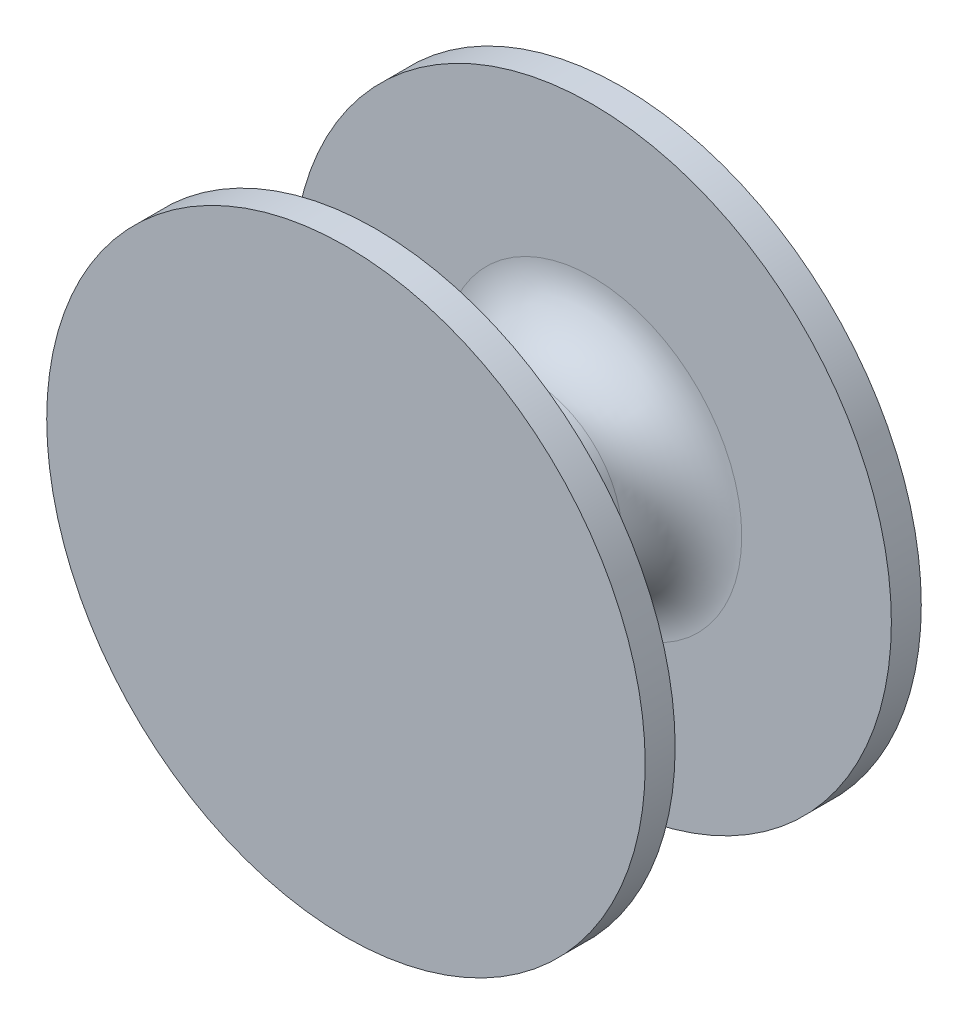
from build123d import *

# Parameters (mm, degrees)
SKETCH7_R      = 5
EXTRUDE5_DEPTH = 2.30625
SKETCH8_W      = 3.5
SKETCH8_H      = 3.6125
FILLET1_R      = 1


with BuildPart() as part:
    # Sketch7 → Extrude5 (new body, symmetric)
    with BuildSketch(Plane.XY):
        Circle(SKETCH7_R)
    extrude(amount=EXTRUDE5_DEPTH, both=True)

    # Sketch8 → Cut-Revolve1 (revolve, cut)
    with BuildSketch(Plane(origin=(0, 0, 0), x_dir=(1, 0, 0), z_dir=(0, 1, 0)), mode=Mode.PRIVATE) as cut_revolve1_sk:
        with Locations((-3.25, 0)):
            Rectangle(SKETCH8_W, SKETCH8_H)
    revolve(cut_revolve1_sk.sketch.rotate(Axis((0, 0, 0), (0, 0, -1)), 180), axis=Axis((0, 0, 0), (0, 0, -1)), mode=Mode.SUBTRACT)  # turned: the seam where the file's is

    # Fillet1
    fillet1_edges = [part.edges().sort_by_distance(p)[0] for p in [
        (-1.5, 0, 1.80625),
        (-1.5, 0, -1.80625),
    ]]
    fillet(fillet1_edges, radius=FILLET1_R)


solid = part.part
